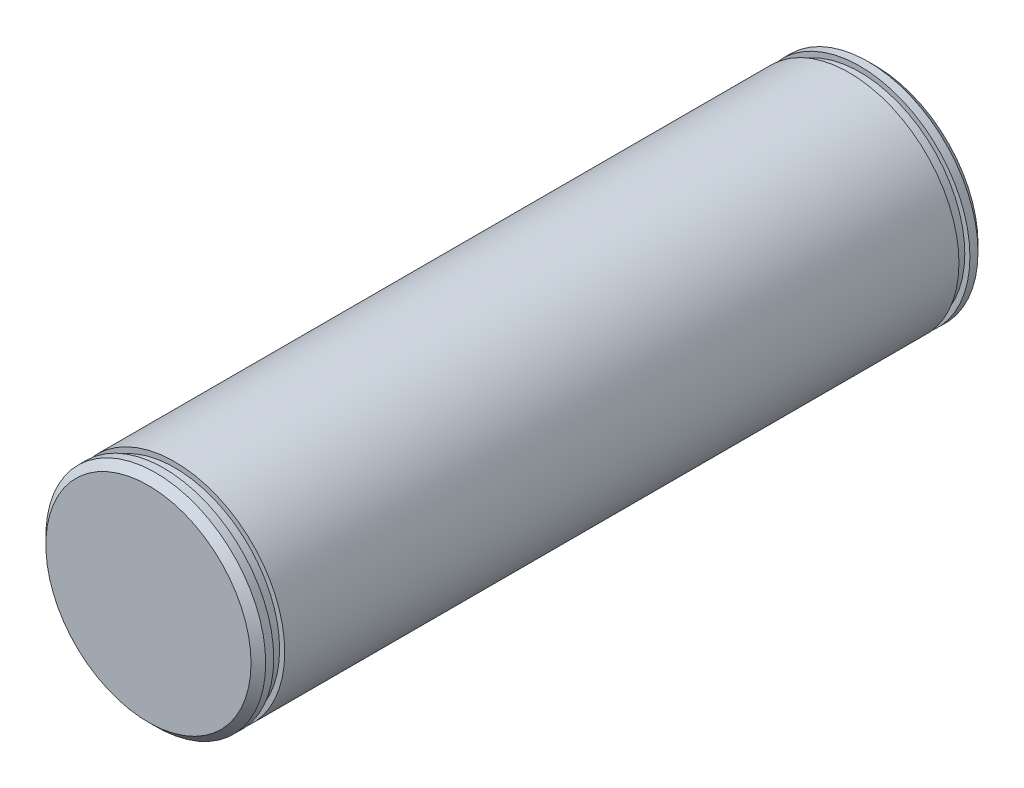
from build123d import *

# Parameters (mm, degrees)
SZKIC1_R                   = 15
WYCI_GNI_CIE_PROSTE1_DEPTH = 46
SZKIC2_R                   = 14.3
WYCI_GNI_CIE_PROSTE2_DEPTH = 1.5
SZKIC3_R                   = 15
WYCI_GNI_CIE_PROSTE3_DEPTH = 2.1
FAZA1_SIZE                 = 1


with BuildPart() as part:
    # Szkic1 → Wyciągnięcie proste1 (new body)
    with BuildSketch(Plane.XY):
        Circle(SZKIC1_R)
    extrude(amount=WYCI_GNI_CIE_PROSTE1_DEPTH)

    # Szkic2 → Wyciągnięcie proste2 (add)
    with BuildSketch(Plane.XY.offset(46)):
        Circle(SZKIC2_R)
    extrude(amount=WYCI_GNI_CIE_PROSTE2_DEPTH)

    # Szkic3 → Wyciągnięcie proste3 (add)
    with BuildSketch(Plane.XY.offset(47.5)):
        Circle(SZKIC3_R)
    extrude(amount=WYCI_GNI_CIE_PROSTE3_DEPTH)

    # Faza1
    faza1_edges = [part.edges().sort_by_distance(p)[0] for p in [
        (-15, 0, 49.6),
    ]]
    chamfer(faza1_edges, length=FAZA1_SIZE)

    # Odbicie lustrzane1: part across plane


with BuildPart() as part_1:
    add(part.part)
    add(part.part.mirror(Plane(origin=(0, 0, 0), x_dir=(1, 0, 0), z_dir=(0, 0, -1))))


solid = part_1.part
